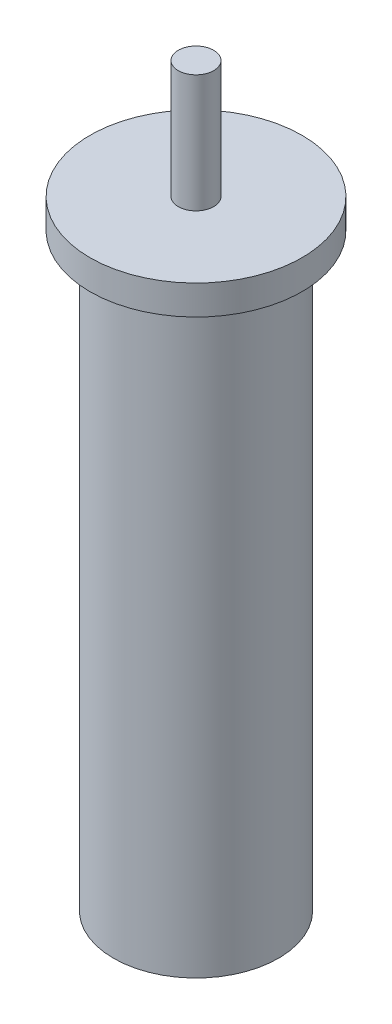
from build123d import *

# Parameters (mm, degrees)
SKETCH1_R           = 14
BOSS_EXTRUDE1_DEPTH = 100
SKETCH2_R           = 18
BOSS_EXTRUDE2_DEPTH = 5
SKETCH3_R           = 3
BOSS_EXTRUDE3_DEPTH = 20


with BuildPart() as part:
    # Sketch1 → Boss-Extrude1 (new body)
    with BuildSketch(Plane(origin=(0, 0, 0), x_dir=(1, 0, 0), z_dir=(0, 1, 0))):
        Circle(SKETCH1_R)
    extrude(amount=BOSS_EXTRUDE1_DEPTH)

    # Sketch2 → Boss-Extrude2 (add)
    with BuildSketch(Plane(origin=(0, 100, 0), x_dir=(1, 0, 0), z_dir=(0, 1, 0))):
        Circle(SKETCH2_R)
    extrude(amount=BOSS_EXTRUDE2_DEPTH)

    # Sketch3 → Boss-Extrude3 (add)
    with BuildSketch(Plane(origin=(0, 105, 0), x_dir=(1, 0, 0), z_dir=(0, 1, 0))):
        Circle(SKETCH3_R)
    extrude(amount=BOSS_EXTRUDE3_DEPTH)


solid = part.part
